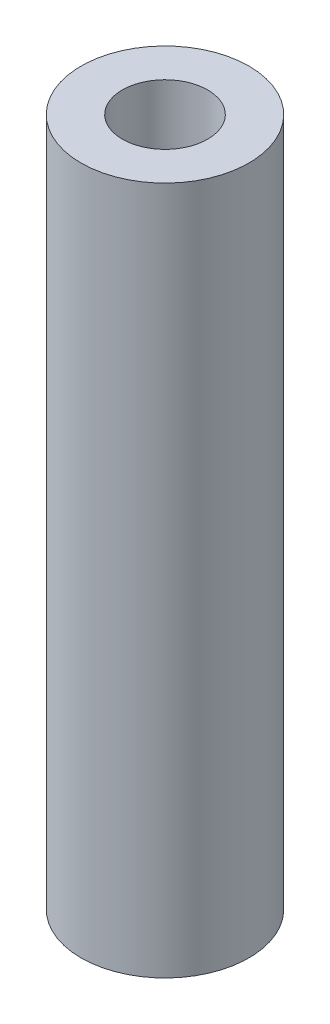
from build123d import *

# Parameters (mm, degrees)
SKETCH1_R           = 3.05
SKETCH1_R_2         = 1.55
BOSS_EXTRUDE1_DEPTH = 25


with BuildPart() as part:
    # Sketch1 → Boss-Extrude1 (new body)
    with BuildSketch(Plane(origin=(0, 0, 0), x_dir=(1, 0, 0), z_dir=(0, 1, 0))):
        Circle(SKETCH1_R)
        Circle(SKETCH1_R_2, mode=Mode.SUBTRACT)
    extrude(amount=BOSS_EXTRUDE1_DEPTH)


solid = part.part
